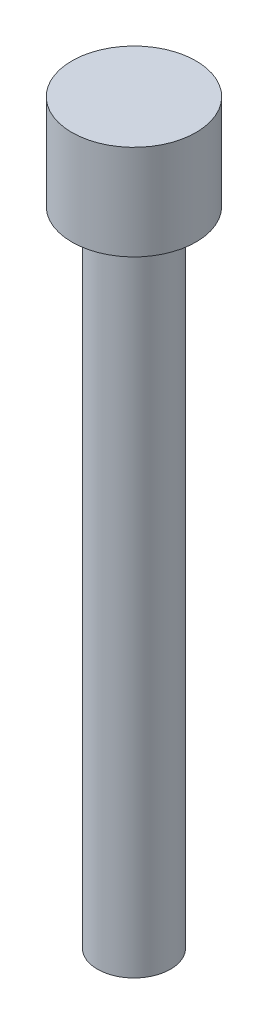
from build123d import *

# Parameters (mm, degrees)
SKETCH1_R           = 2.5
BOSS_EXTRUDE1_DEPTH = 44
SKETCH2_R           = 4.25
BOSS_EXTRUDE2_DEPTH = 6.5


with BuildPart() as part:
    # Sketch1 → Boss-Extrude1 (new body)
    with BuildSketch(Plane(origin=(0, 0, 0), x_dir=(1, 0, 0), z_dir=(0, 1, 0))):
        Circle(SKETCH1_R)
    extrude(amount=BOSS_EXTRUDE1_DEPTH)

    # Sketch2 → Boss-Extrude2 (add)
    with BuildSketch(Plane(origin=(0, 44, 0), x_dir=(1, 0, 0), z_dir=(0, 1, 0))):
        Circle(SKETCH2_R)
    extrude(amount=BOSS_EXTRUDE2_DEPTH)


solid = part.part
